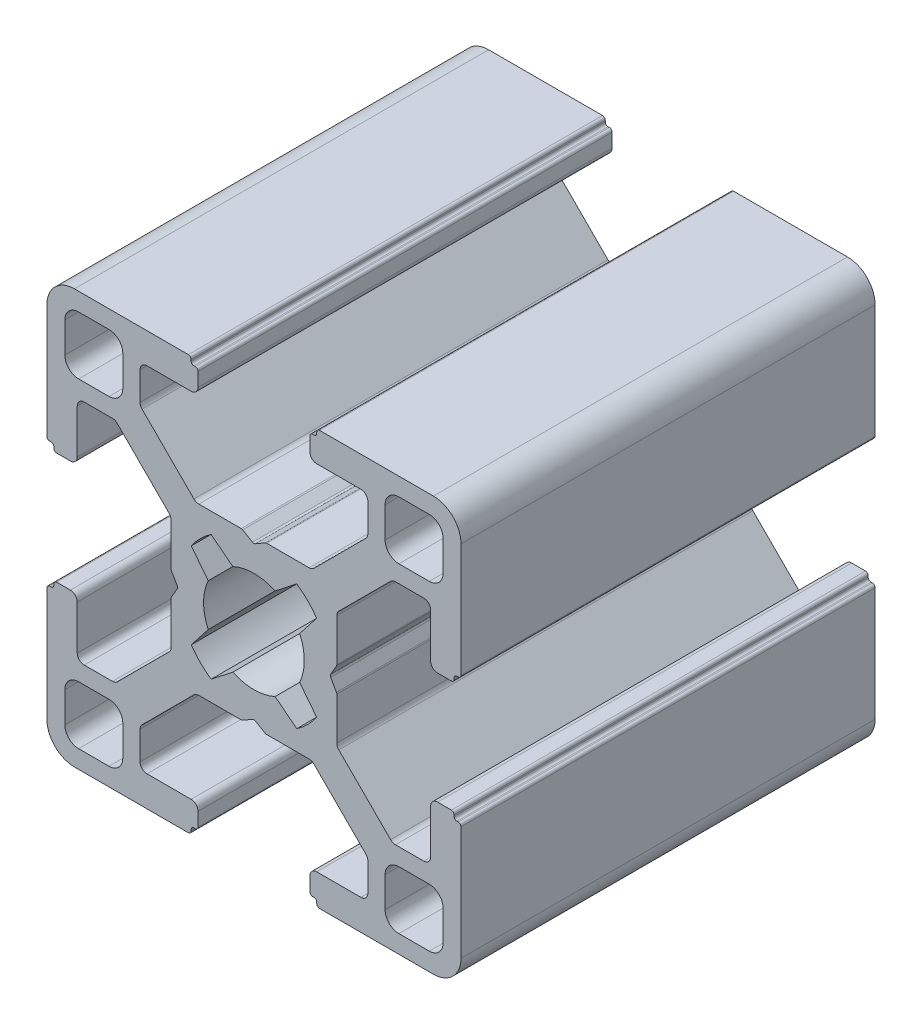
from build123d import *

# Parameters (mm, degrees)
EXTRUDE_1_DEPTH = 30


with BuildPart() as part:
    # Эскиз1 → Бобышка-Вытянуть1 (new body)
    with BuildSketch(Plane.XY):
        with BuildLine():
            Line((-5.557735027, 0.1), (-5.973205081, 0.819615242))
            ThreePointArc((-5.973205081, 0.819615242), (-5.993185165, 0.867851433), (-6, 0.919615242))
            Line((-6, 0.919615242), (-6, 3.996841995))
            ThreePointArc((-6, 3.996841995), (-6.038060234, 4.188183711), (-6.146446609, 4.350395385))
            Line((-6.146446609, 4.350395385), (-9.899604615, 8.103553391))
            ThreePointArc((-9.899604615, 8.103553391), (-10.061816289, 8.211939766), (-10.253158005, 8.25))
            Line((-10.253158005, 8.25), (-12.3, 8.25))
            ThreePointArc((-12.3, 8.25), (-12.653553391, 8.103553391), (-12.8, 7.75))
            Line((-12.8, 7.75), (-12.8, 4.55))
            ThreePointArc((-12.8, 4.55), (-12.946446609, 4.196446609), (-13.3, 4.05))
            Line((-13.3, 4.05), (-14.3, 4.05))
            ThreePointArc((-14.3, 4.05), (-14.441421356, 4.108578644), (-14.5, 4.25))
            Line((-14.5, 4.25), (-14.5, 4.35))
            ThreePointArc((-14.5, 4.35), (-14.558578644, 4.491421356), (-14.7, 4.55))
            Line((-14.7, 4.55), (-14.8, 4.55))
            ThreePointArc((-14.8, 4.55), (-14.941421356, 4.608578644), (-15, 4.75))
            Line((-15, 4.75), (-15, 13))
            ThreePointArc((-15, 13), (-14.414213562, 14.414213562), (-13, 15))
            Line((-13, 15), (-4.75, 15))
            ThreePointArc((-4.75, 15), (-4.608578644, 14.941421356), (-4.55, 14.8))
            Line((-4.55, 14.8), (-4.55, 14.7))
            ThreePointArc((-4.55, 14.7), (-4.491421356, 14.558578644), (-4.35, 14.5))
            Line((-4.35, 14.5), (-4.25, 14.5))
            ThreePointArc((-4.25, 14.5), (-4.108578644, 14.441421356), (-4.05, 14.3))
            Line((-4.05, 14.3), (-4.05, 13.3))
            ThreePointArc((-4.05, 13.3), (-4.196446609, 12.946446609), (-4.55, 12.8))
            Line((-4.55, 12.8), (-7.75, 12.8))
            ThreePointArc((-7.75, 12.8), (-8.103553391, 12.653553391), (-8.25, 12.3))
            Line((-8.25, 12.3), (-8.25, 10.253158005))
            ThreePointArc((-8.25, 10.253158005), (-8.211939766, 10.061816289), (-8.103553391, 9.899604615))
            Line((-8.103553391, 9.899604615), (-4.350395385, 6.146446609))
            ThreePointArc((-4.350395385, 6.146446609), (-4.188183711, 6.038060234), (-3.996841995, 6))
            Line((-3.996841995, 6), (-0.919615242, 6))
            ThreePointArc((-0.919615242, 6), (-0.867851433, 5.993185165), (-0.819615242, 5.973205081))
            Line((-0.819615242, 5.973205081), (-0.1, 5.557735027))
            ThreePointArc((-0.1, 5.557735027), (0, 5.530940108), (0.1, 5.557735027))
            Line((0.1, 5.557735027), (0.819615242, 5.973205081))
            ThreePointArc((0.819615242, 5.973205081), (0.867851433, 5.993185165), (0.919615242, 6))
            Line((0.919615242, 6), (3.996841995, 6))
            ThreePointArc((3.996841995, 6), (4.188183711, 6.038060234), (4.350395385, 6.146446609))
            Line((4.350395385, 6.146446609), (8.103553391, 9.899604615))
            ThreePointArc((8.103553391, 9.899604615), (8.211939766, 10.061816289), (8.25, 10.253158005))
            Line((8.25, 10.253158005), (8.25, 12.3))
            ThreePointArc((8.25, 12.3), (8.103553391, 12.653553391), (7.75, 12.8))
            Line((7.75, 12.8), (4.55, 12.8))
            ThreePointArc((4.55, 12.8), (4.196446609, 12.946446609), (4.05, 13.3))
            Line((4.05, 13.3), (4.05, 14.3))
            ThreePointArc((4.05, 14.3), (4.108578644, 14.441421356), (4.25, 14.5))
            Line((4.25, 14.5), (4.35, 14.5))
            ThreePointArc((4.35, 14.5), (4.491421356, 14.558578644), (4.55, 14.7))
            Line((4.55, 14.7), (4.55, 14.8))
            ThreePointArc((4.55, 14.8), (4.608578644, 14.941421356), (4.75, 15))
            Line((4.75, 15), (13, 15))
            ThreePointArc((13, 15), (14.414213562, 14.414213562), (15, 13))
            Line((15, 13), (15, 4.75))
            ThreePointArc((15, 4.75), (14.941421356, 4.608578644), (14.8, 4.55))
            Line((14.8, 4.55), (14.7, 4.55))
            ThreePointArc((14.7, 4.55), (14.558578644, 4.491421356), (14.5, 4.35))
            Line((14.5, 4.35), (14.5, 4.25))
            ThreePointArc((14.5, 4.25), (14.441421356, 4.108578644), (14.3, 4.05))
            Line((14.3, 4.05), (13.3, 4.05))
            ThreePointArc((13.3, 4.05), (12.946446609, 4.196446609), (12.8, 4.55))
            Line((12.8, 4.55), (12.8, 7.75))
            ThreePointArc((12.8, 7.75), (12.653553391, 8.103553391), (12.3, 8.25))
            Line((12.3, 8.25), (10.253158005, 8.25))
            ThreePointArc((10.253158005, 8.25), (10.061816289, 8.211939766), (9.899604615, 8.103553391))
            Line((9.899604615, 8.103553391), (6.146446609, 4.350395385))
            ThreePointArc((6.146446609, 4.350395385), (6.038060234, 4.188183711), (6, 3.996841995))
            Line((6, 3.996841995), (6, 0.919615242))
            ThreePointArc((6, 0.919615242), (5.993185165, 0.867851433), (5.973205081, 0.819615242))
            Line((5.973205081, 0.819615242), (5.557735027, 0.1))
            ThreePointArc((5.557735027, 0.1), (5.530940108, 0), (5.557735027, -0.1))
            Line((5.557735027, -0.1), (5.973205081, -0.819615242))
            ThreePointArc((5.973205081, -0.819615242), (5.993185165, -0.867851433), (6, -0.919615242))
            Line((6, -0.919615242), (6, -3.996841995))
            ThreePointArc((6, -3.996841995), (6.038060234, -4.188183711), (6.146446609, -4.350395385))
            Line((6.146446609, -4.350395385), (9.899604615, -8.103553391))
            ThreePointArc((9.899604615, -8.103553391), (10.061816289, -8.211939766), (10.253158005, -8.25))
            Line((10.253158005, -8.25), (12.3, -8.25))
            ThreePointArc((12.3, -8.25), (12.653553391, -8.103553391), (12.8, -7.75))
            Line((12.8, -7.75), (12.8, -4.55))
            ThreePointArc((12.8, -4.55), (12.946446609, -4.196446609), (13.3, -4.05))
            Line((13.3, -4.05), (14.3, -4.05))
            ThreePointArc((14.3, -4.05), (14.441421356, -4.108578644), (14.5, -4.25))
            Line((14.5, -4.25), (14.5, -4.35))
            ThreePointArc((14.5, -4.35), (14.558578644, -4.491421356), (14.7, -4.55))
            Line((14.7, -4.55), (14.8, -4.55))
            ThreePointArc((14.8, -4.55), (14.941421356, -4.608578644), (15, -4.75))
            Line((15, -4.75), (15, -13))
            ThreePointArc((15, -13), (14.414213562, -14.414213562), (13, -15))
            Line((13, -15), (4.75, -15))
            ThreePointArc((4.75, -15), (4.608578644, -14.941421356), (4.55, -14.8))
            Line((4.55, -14.8), (4.55, -14.7))
            ThreePointArc((4.55, -14.7), (4.491421356, -14.558578644), (4.35, -14.5))
            Line((4.35, -14.5), (4.25, -14.5))
            ThreePointArc((4.25, -14.5), (4.108578644, -14.441421356), (4.05, -14.3))
            Line((4.05, -14.3), (4.05, -13.3))
            ThreePointArc((4.05, -13.3), (4.196446609, -12.946446609), (4.55, -12.8))
            Line((4.55, -12.8), (7.75, -12.8))
            ThreePointArc((7.75, -12.8), (8.103553391, -12.653553391), (8.25, -12.3))
            Line((8.25, -12.3), (8.25, -10.253158005))
            ThreePointArc((8.25, -10.253158005), (8.211939766, -10.061816289), (8.103553391, -9.899604615))
            Line((8.103553391, -9.899604615), (4.350395385, -6.146446609))
            ThreePointArc((4.350395385, -6.146446609), (4.188183711, -6.038060234), (3.996841995, -6))
            Line((3.996841995, -6), (0.919615242, -6))
            ThreePointArc((0.919615242, -6), (0.867851433, -5.993185165), (0.819615242, -5.973205081))
            Line((0.819615242, -5.973205081), (0.1, -5.557735027))
            ThreePointArc((0.1, -5.557735027), (0, -5.530940108), (-0.1, -5.557735027))
            Line((-0.1, -5.557735027), (-0.819615242, -5.973205081))
            ThreePointArc((-0.819615242, -5.973205081), (-0.867851433, -5.993185165), (-0.919615242, -6))
            Line((-0.919615242, -6), (-3.996841995, -6))
            ThreePointArc((-3.996841995, -6), (-4.188183711, -6.038060234), (-4.350395385, -6.146446609))
            Line((-4.350395385, -6.146446609), (-8.103553391, -9.899604615))
            ThreePointArc((-8.103553391, -9.899604615), (-8.211939766, -10.061816289), (-8.25, -10.253158005))
            Line((-8.25, -10.253158005), (-8.25, -12.3))
            ThreePointArc((-8.25, -12.3), (-8.103553391, -12.653553391), (-7.75, -12.8))
            Line((-7.75, -12.8), (-4.55, -12.8))
            ThreePointArc((-4.55, -12.8), (-4.196446609, -12.946446609), (-4.05, -13.3))
            Line((-4.05, -13.3), (-4.05, -14.3))
            ThreePointArc((-4.05, -14.3), (-4.108578644, -14.441421356), (-4.25, -14.5))
            Line((-4.25, -14.5), (-4.35, -14.5))
            ThreePointArc((-4.35, -14.5), (-4.491421356, -14.558578644), (-4.55, -14.7))
            Line((-4.55, -14.7), (-4.55, -14.8))
            ThreePointArc((-4.55, -14.8), (-4.608578644, -14.941421356), (-4.75, -15))
            Line((-4.75, -15), (-13, -15))
            ThreePointArc((-13, -15), (-14.414213562, -14.414213562), (-15, -13))
            Line((-15, -13), (-15, -4.75))
            ThreePointArc((-15, -4.75), (-14.941421356, -4.608578644), (-14.8, -4.55))
            Line((-14.8, -4.55), (-14.7, -4.55))
            ThreePointArc((-14.7, -4.55), (-14.558578644, -4.491421356), (-14.5, -4.35))
            Line((-14.5, -4.35), (-14.5, -4.25))
            ThreePointArc((-14.5, -4.25), (-14.441421356, -4.108578644), (-14.3, -4.05))
            Line((-14.3, -4.05), (-13.3, -4.05))
            ThreePointArc((-13.3, -4.05), (-12.946446609, -4.196446609), (-12.8, -4.55))
            Line((-12.8, -4.55), (-12.8, -7.75))
            ThreePointArc((-12.8, -7.75), (-12.653553391, -8.103553391), (-12.3, -8.25))
            Line((-12.3, -8.25), (-10.253158005, -8.25))
            ThreePointArc((-10.253158005, -8.25), (-10.061816289, -8.211939766), (-9.899604615, -8.103553391))
            Line((-9.899604615, -8.103553391), (-6.146446609, -4.350395385))
            ThreePointArc((-6.146446609, -4.350395385), (-6.038060234, -4.188183711), (-6, -3.996841995))
            Line((-6, -3.996841995), (-6, -0.919615242))
            ThreePointArc((-6, -0.919615242), (-5.993185165, -0.867851433), (-5.973205081, -0.819615242))
            Line((-5.973205081, -0.819615242), (-5.557735027, -0.1))
            ThreePointArc((-5.557735027, -0.1), (-5.530940108, 0), (-5.557735027, 0.1))
        make_face()
        with BuildLine():
            Line((-4.54098589, 3.103135052), (-3.313131952, 1.531553678))
            ThreePointArc((-3.313131952, 1.531553678), (-3.65, 0), (-3.313131952, -1.531553678))
            Line((-3.313131952, -1.531553678), (-4.54098589, -3.103135052))
            ThreePointArc((-4.54098589, -3.103135052), (-3.889087297, -3.889087297), (-3.103135052, -4.54098589))
            Line((-3.103135052, -4.54098589), (-1.531553678, -3.313131952))
            ThreePointArc((-1.531553678, -3.313131952), (0, -3.65), (1.531553678, -3.313131952))
            Line((1.531553678, -3.313131952), (3.103135052, -4.54098589))
            ThreePointArc((3.103135052, -4.54098589), (3.889087297, -3.889087297), (4.54098589, -3.103135052))
            Line((4.54098589, -3.103135052), (3.313131952, -1.531553678))
            ThreePointArc((3.313131952, -1.531553678), (3.65, 0), (3.313131952, 1.531553678))
            Line((3.313131952, 1.531553678), (4.54098589, 3.103135052))
            ThreePointArc((4.54098589, 3.103135052), (3.889087297, 3.889087297), (3.103135052, 4.54098589))
            Line((3.103135052, 4.54098589), (1.531553678, 3.313131952))
            ThreePointArc((1.531553678, 3.313131952), (0, 3.65), (-1.531553678, 3.313131952))
            Line((-1.531553678, 3.313131952), (-3.103135052, 4.54098589))
            ThreePointArc((-3.103135052, 4.54098589), (-3.889087297, 3.889087297), (-4.54098589, 3.103135052))
        make_face(mode=Mode.SUBTRACT)
        with BuildLine():
            Line((-13.7, 12.7), (-13.7, 10.5))
            ThreePointArc((-13.7, 10.5), (-13.407106781, 9.792893219), (-12.7, 9.5))
            Line((-12.7, 9.5), (-10.5, 9.5))
            ThreePointArc((-10.5, 9.5), (-9.792893219, 9.792893219), (-9.5, 10.5))
            Line((-9.5, 10.5), (-9.5, 12.7))
            ThreePointArc((-9.5, 12.7), (-9.792893219, 13.407106781), (-10.5, 13.7))
            Line((-10.5, 13.7), (-12.7, 13.7))
            ThreePointArc((-12.7, 13.7), (-13.407106781, 13.407106781), (-13.7, 12.7))
        make_face(mode=Mode.SUBTRACT)
        with BuildLine():
            Line((-9.5, -10.5), (-9.5, -12.7))
            ThreePointArc((-9.5, -12.7), (-9.792893219, -13.407106781), (-10.5, -13.7))
            Line((-10.5, -13.7), (-12.7, -13.7))
            ThreePointArc((-12.7, -13.7), (-13.407106781, -13.407106781), (-13.7, -12.7))
            Line((-13.7, -12.7), (-13.7, -10.5))
            ThreePointArc((-13.7, -10.5), (-13.407106781, -9.792893219), (-12.7, -9.5))
            Line((-12.7, -9.5), (-10.5, -9.5))
            ThreePointArc((-10.5, -9.5), (-9.792893219, -9.792893219), (-9.5, -10.5))
        make_face(mode=Mode.SUBTRACT)
        with BuildLine():
            Line((13.7, -12.7), (13.7, -10.5))
            ThreePointArc((13.7, -10.5), (13.407106781, -9.792893219), (12.7, -9.5))
            Line((12.7, -9.5), (10.5, -9.5))
            ThreePointArc((10.5, -9.5), (9.792893219, -9.792893219), (9.5, -10.5))
            Line((9.5, -10.5), (9.5, -12.7))
            ThreePointArc((9.5, -12.7), (9.792893219, -13.407106781), (10.5, -13.7))
            Line((10.5, -13.7), (12.7, -13.7))
            ThreePointArc((12.7, -13.7), (13.407106781, -13.407106781), (13.7, -12.7))
        make_face(mode=Mode.SUBTRACT)
        with BuildLine():
            Line((9.5, 10.5), (9.5, 12.7))
            ThreePointArc((9.5, 12.7), (9.792893219, 13.407106781), (10.5, 13.7))
            Line((10.5, 13.7), (12.7, 13.7))
            ThreePointArc((12.7, 13.7), (13.407106781, 13.407106781), (13.7, 12.7))
            Line((13.7, 12.7), (13.7, 10.5))
            ThreePointArc((13.7, 10.5), (13.407106781, 9.792893219), (12.7, 9.5))
            Line((12.7, 9.5), (10.5, 9.5))
            ThreePointArc((10.5, 9.5), (9.792893219, 9.792893219), (9.5, 10.5))
        make_face(mode=Mode.SUBTRACT)
    extrude(amount=EXTRUDE_1_DEPTH)


solid = part.part
